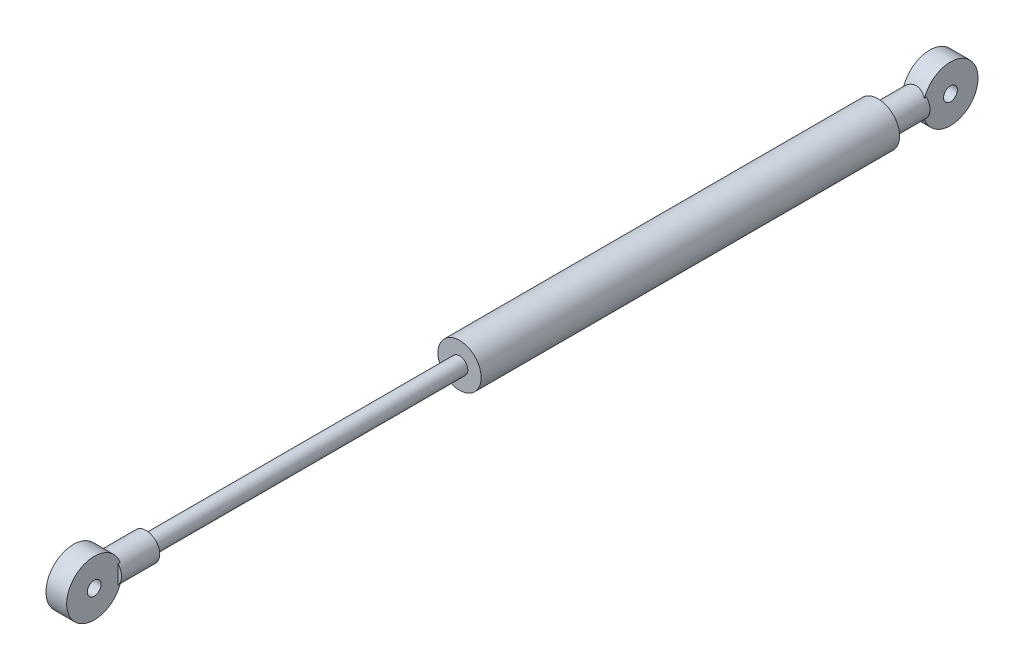
from build123d import *

# Parameters (mm, degrees)
SKETCH1_R             = 6
SKETCH1_R_2           = 1.5
BOSS_EXTRUDE1_DEPTH   = 2.25
BOSS_EXTRUDE1_2_DEPTH = 2.25


with BuildPart() as part:
    # Sketch1 → Boss-Extrude1 (new, symmetric)
    with BuildSketch(Plane(origin=(0, 0, 0), x_dir=(0, 0, -1), z_dir=(1, 0, 0))):
        Circle(SKETCH1_R)
        Circle(SKETCH1_R_2, mode=Mode.SUBTRACT)
    extrude(amount=BOSS_EXTRUDE1_DEPTH, both=True)

    # Sketch1_3 → Revolve1 (revolve)
    with BuildSketch(Plane(origin=(0, 0, 0), x_dir=(0, 0, -1), z_dir=(1, 0, 0))):
        with BuildLine():
            Line((-5.196152423, 3), (-13.5, 3))
            Line((-13.5, 3), (-13.5, 4.7))
            Line((-13.5, 4.7), (-104.5, 4.7))
            Line((-104.5, 4.7), (-104.5, 0))
            Line((-104.5, 0), (-6, 0))
            ThreePointArc((-6, 0), (-5.795554958, 1.552914271), (-5.196152423, 3))
        make_face()
    revolve(axis=Axis((0, 0, 13.5), (0, 0, 1)))


with BuildPart() as body_2:
    # Sketch1 → Boss-Extrude1 2 (new, symmetric)
    with BuildSketch(Plane(origin=(0, 0, 0), x_dir=(0, 0, -1), z_dir=(1, 0, 0))):
        with Locations((-186.181752409, 0)):
            Circle(SKETCH1_R)
        with Locations((-186.181752409, 0)):
            Circle(SKETCH1_R_2, mode=Mode.SUBTRACT)
    extrude(amount=BOSS_EXTRUDE1_2_DEPTH, both=True)


with BuildPart() as body_3:
    # Sketch1_62 → Revolve2 (revolve)
    with BuildSketch(Plane(origin=(0, 0, 0), x_dir=(0, 0, -1), z_dir=(1, 0, 0))):
        Polygon((-104.5, 0), (-104.5, 1.8), (-172.681752409, 1.8), (-172.681752409, 3), (-180.985599986, 3), (-180.985599986, 0), align=None)
    revolve(axis=Axis((0, 0, 172.681752409), (0, 0, -1)))

    # Combine1: union body 2
    add(body_2.part)


solid = Compound([part.part, body_3.part])
